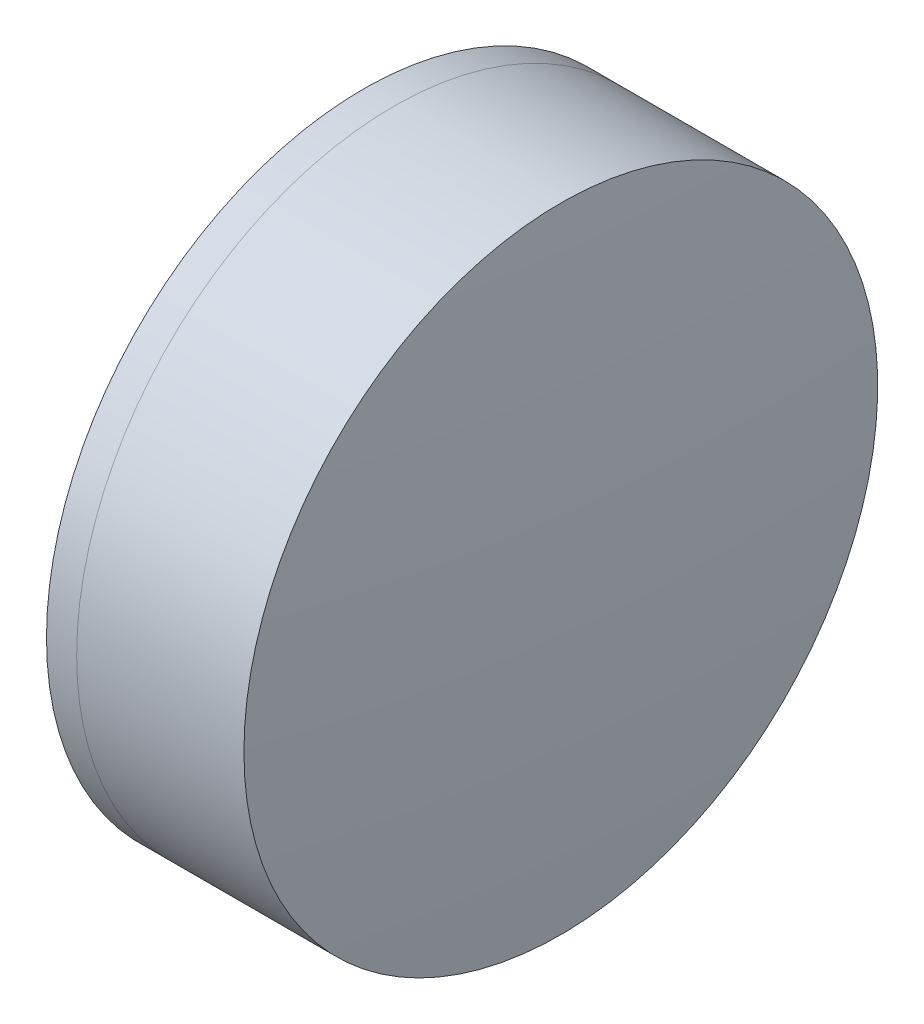
from build123d import *


with BuildPart() as part:
    # 草图1 one side → 旋转1 (revolve)
    with BuildSketch(Plane(origin=(0, 0, 0), x_dir=(1, 0, 0), z_dir=(0, 1, 0)), mode=Mode.PRIVATE) as revolve_1_sk:
        with BuildLine():
            ThreePointArc((268.591783329, 6.35), (267.263116652, 3.297763294), (266.80895665, 0))
            Line((266.80895665, 0), (271.30895665, 0))
            ThreePointArc((271.30895665, 0), (270.766973414, 3.346087086), (269.196447446, 6.35))
            Line((269.196447446, 6.35), (268.591783329, 6.35))
        make_face()
    revolve(revolve_1_sk.sketch.rotate(Axis((124.523309526, 0, 0), (1, 0, 0)), 180), axis=Axis((124.523309526, 0, 0), (1, 0, 0)))  # turned: the seam where the file's is


with BuildPart() as body_2:
    # 草图2 one side → 旋转3 (revolve)
    with BuildSketch(Plane(origin=(0, 0, 0), x_dir=(1, 0, 0), z_dir=(0, 1, 0)), mode=Mode.PRIVATE) as revolve_3_sk:
        with BuildLine():
            Line((272.548035592, 6.35), (269.196447446, 6.35))
            ThreePointArc((269.196447446, 6.35), (270.766973414, 3.346087086), (271.30895665, 0))
            Line((271.30895665, 0), (272.80895665, 0))
            ThreePointArc((272.80895665, 0), (272.743698876, 3.177679177), (272.548035592, 6.35))
        make_face()
    revolve(revolve_3_sk.sketch.rotate(Axis((-0.551919993, 0, 0), (1, 0, 0)), 180), axis=Axis((-0.551919993, 0, 0), (1, 0, 0)))  # turned: the seam where the file's is


solid = Compound([part.part, body_2.part])
